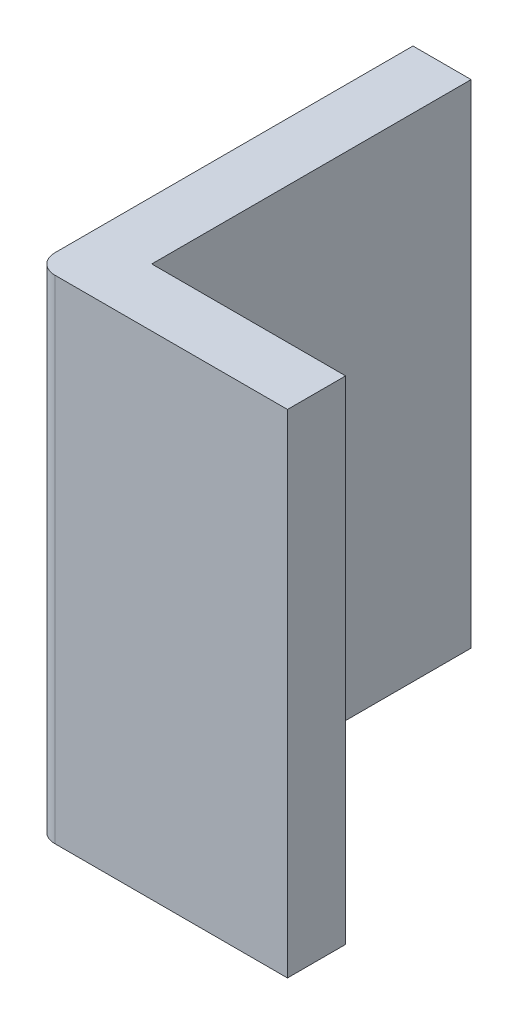
from build123d import *

# Parameters (mm, degrees)
BOSS_EXTRU_1_DEPTH = 2.54


with BuildPart() as part:
    # Esquisse1 → Boss.-Extru.1 (new body)
    with BuildSketch(Plane(origin=(0, 0, 0), x_dir=(1, 0, 0), z_dir=(0, 1, 0))):
        with BuildLine():
            Line((0, 0), (0, 1.647444936))
            Line((0, 1.647444936), (-0.3, 1.647444936))
            Line((-0.3, 1.647444936), (-0.3, -0.2))
            ThreePointArc((-0.3, -0.2), (-0.270710678, -0.270710678), (-0.2, -0.3))
            Line((-0.2, -0.3), (1, -0.3))
            Line((1, -0.3), (1, 0))
            Line((1, 0), (0, 0))
        make_face()
    extrude(amount=BOSS_EXTRU_1_DEPTH)


solid = part.part
